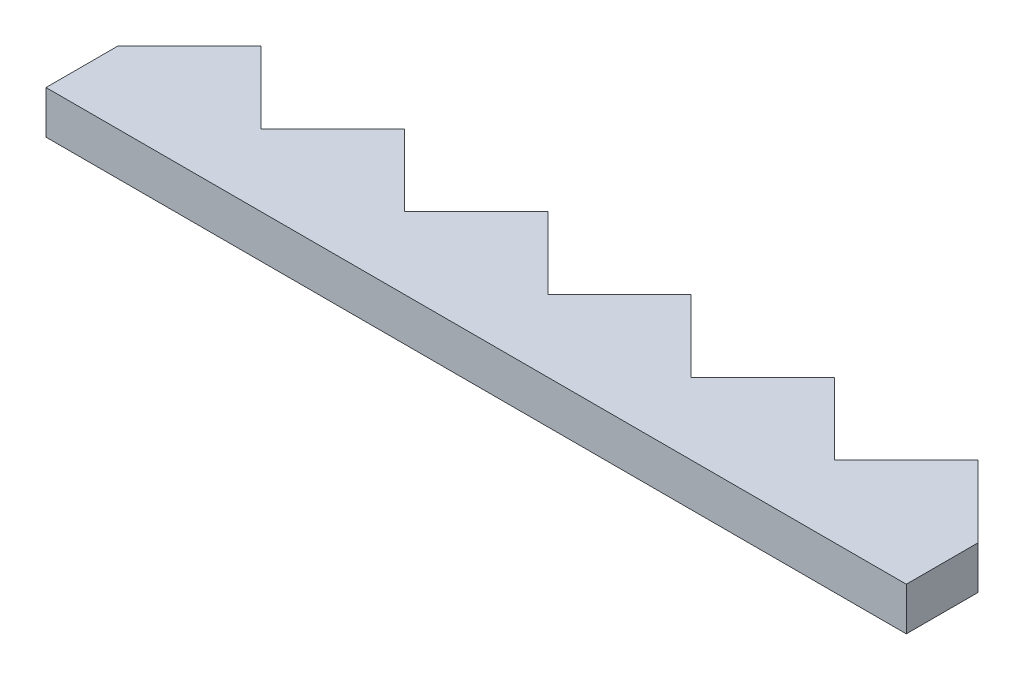
from build123d import *

# Parameters (mm, degrees)
BOSS_EXTRUDE1_DEPTH = 3


with BuildPart() as part:
    # Sketch1 → Boss-Extrude1 (new body)
    with BuildSketch(Plane(origin=(0, 0, 0), x_dir=(1, 0, 0), z_dir=(0, 1, 0))):
        Polygon((0, 5), (5, 10), (10, 5), (15, 10), (20, 5), (25, 10), (30, 5), (35, 10), (40, 5), (45, 10), (50, 5), (55, 10), (60, 5), (60, 0), (0, 0), align=None)
    extrude(amount=BOSS_EXTRUDE1_DEPTH)


solid = part.part
